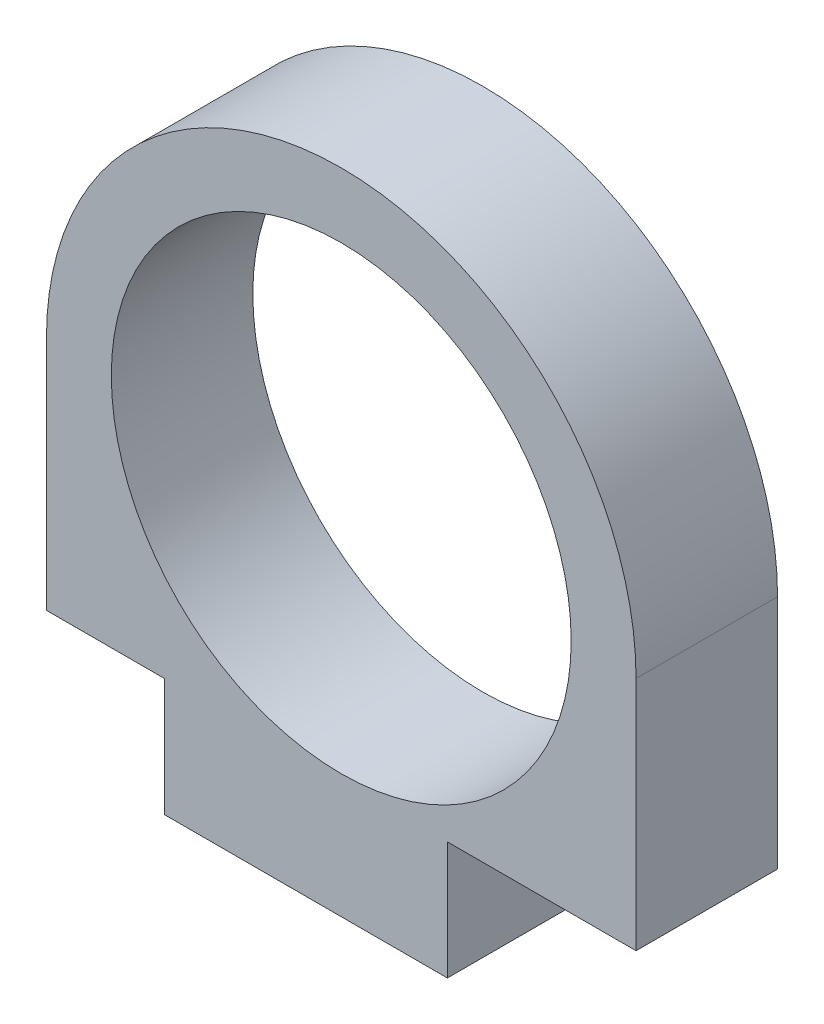
from build123d import *

# Parameters (mm, degrees)
CROQUIS1_R              = 9.75
SALIENTE_EXTRUIR1_DEPTH = 6


with BuildPart() as part:
    # Croquis1 → Saliente-Extruir1 (new body)
    with BuildSketch(Plane.XY):
        with BuildLine():
            ThreePointArc((12.5, 0), (0, 12.5), (-12.5, 0))
            Line((-12.5, 0), (-12.5, -10))
            Line((-12.5, -10), (-7.5, -10))
            Line((-7.5, -10), (-7.5, -15))
            Line((-7.5, -15), (4.5, -15))
            Line((4.5, -15), (4.5, -10))
            Line((4.5, -10), (12.5, -10))
            Line((12.5, -10), (12.5, 0))
        make_face()
        Circle(CROQUIS1_R, mode=Mode.SUBTRACT)
    extrude(amount=SALIENTE_EXTRUIR1_DEPTH)


solid = part.part
